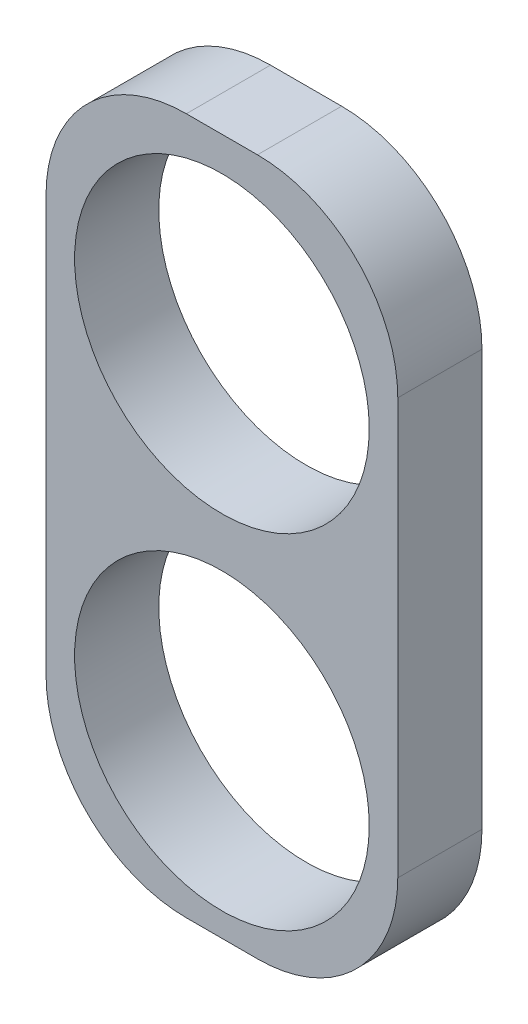
from build123d import *

# Parameters (mm, degrees)
SKETCH1_W           = 5.013785632
SKETCH1_H           = 9.926537354
SKETCH1_R           = 2.1
BOSS_EXTRUDE2_DEPTH = 1.2
FILLET1_R           = 2


with BuildPart() as part:
    # Sketch1 → Boss-Extrude2 (new body)
    with BuildSketch(Plane.XY):
        Rectangle(SKETCH1_W, SKETCH1_H)
        with Locations((0, 2.378079684)):
            Circle(SKETCH1_R, mode=Mode.SUBTRACT)
        with Locations((0, -2.52414688)):
            Circle(SKETCH1_R, mode=Mode.SUBTRACT)
    extrude(amount=BOSS_EXTRUDE2_DEPTH)

    # Fillet1
    fillet1_edges = [part.edges().sort_by_distance(p)[0] for p in [
        (2.506892816, -4.963268677, 0.6),
        (-2.506892816, -4.963268677, 0.6),
        (-2.506892816, 4.963268677, 0.6),
        (2.506892816, 4.963268677, 0.6),
    ]]
    fillet(fillet1_edges, radius=FILLET1_R)


solid = part.part
